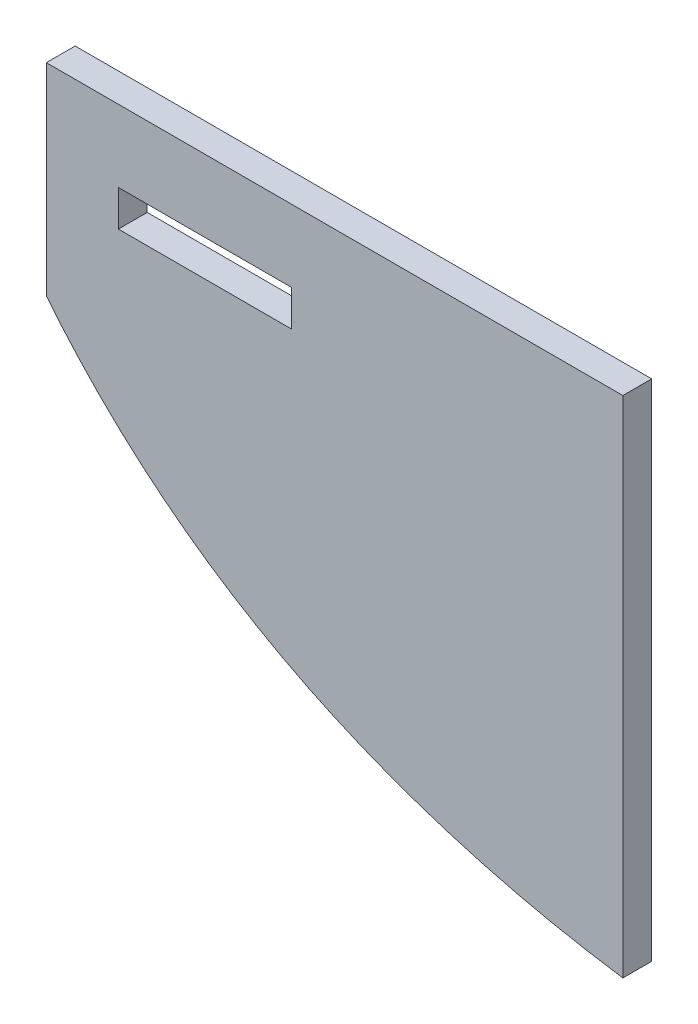
from build123d import *

# Parameters (mm, degrees)
ESQUISSE1_W             = 40
ESQUISSE1_H             = 35
ESQUISSE1_W_2           = 12
ESQUISSE1_H_2           = 2.5
BOSS_EXTRU_1_DEPTH      = 2
ENL_V_MAT_EXTRU_1_DEPTH = 10


with BuildPart() as part:
    # Esquisse1 → Boss.-Extru.1 (new body)
    with BuildSketch(Plane.XY):
        Rectangle(ESQUISSE1_W, ESQUISSE1_H)
        with Locations((-9, 11.25)):
            Rectangle(ESQUISSE1_W_2, ESQUISSE1_H_2, mode=Mode.SUBTRACT)
    extrude(amount=BOSS_EXTRU_1_DEPTH)

    # Esquisse2 → Enlèv. mat.-Extru.1 (cut)
    with BuildSketch(Plane.XY.offset(2)):
        with BuildLine():
            Line((-28.030678158, 16.936481773), (-23.254011087, -35.479522979))
            Line((-23.254011087, -35.479522979), (20, -17.5))
            add(Edge.make_bspline(
                [(20, -17.5), (-15.360660847, -12.269480231), (-28.030678158, 16.936481773)],
                knots=[0, 0, 0, 1, 1, 1], degree=2))
        make_face()
    extrude(amount=-ENL_V_MAT_EXTRU_1_DEPTH, mode=Mode.SUBTRACT)


solid = part.part
